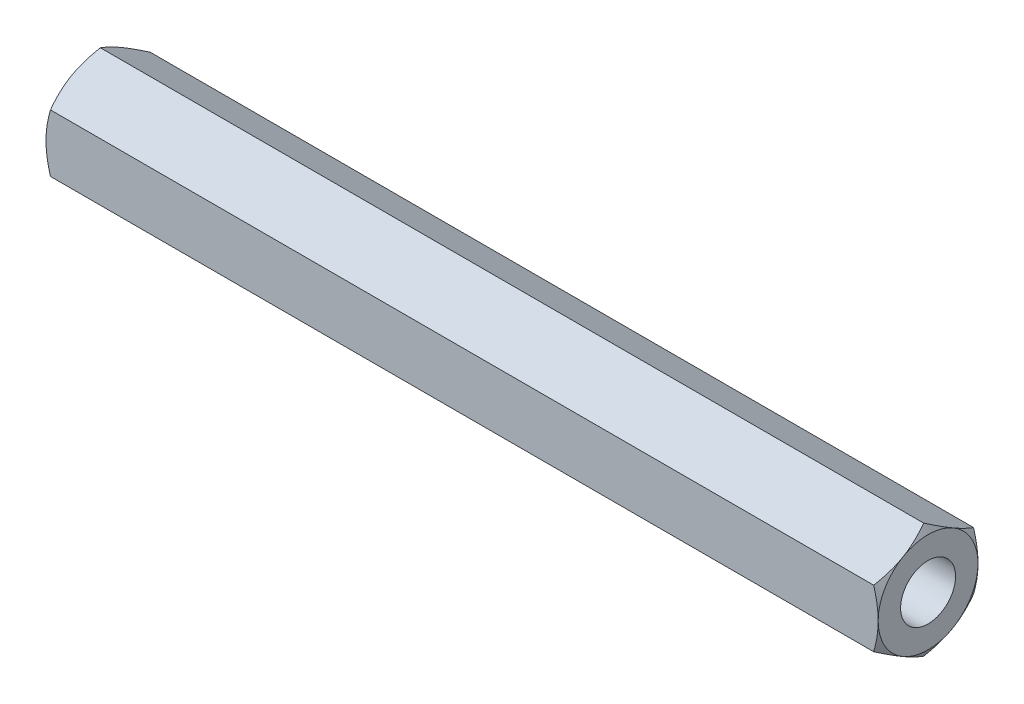
from build123d import *

# Parameters (mm, degrees)
BOSS_EXTRUDE1_DEPTH = 50
SKETCH21_W          = 50
SKETCH21_H          = 3
TAPPED_HOLE4_D      = 3.3
TAPPED_HOLE4_DEPTH  = 11.5
TAPPED_HOLE4_TIP    = 0.991420021
TAPPED_HOLE5_D      = 3.3
TAPPED_HOLE5_DEPTH  = 11.5
TAPPED_HOLE5_TIP    = 0.991420021


with BuildPart() as part:
    # Sketch1 → Boss-Extrude1 (new body)
    with BuildSketch(Plane(origin=(0, 0, 0), x_dir=(0, 0, -1), z_dir=(1, 0, 0))):
        Polygon((0, -3.464101615), (3, -1.732050808), (3, 1.732050808), (0, 3.464101615), (-3, 1.732050808), (-3, -1.732050808), align=None)
    extrude(amount=BOSS_EXTRUDE1_DEPTH)

    # Sketch2 → Cut-Revolve1 (revolve, cut)
    with BuildSketch(Plane.XY):
        Polygon((0, 3.464101615), (0.267949192, 3.464101615), (0, 3), align=None)
        Polygon((49.732050808, 3.464101615), (50, 3), (50, 3.464101615), align=None)
    revolve(axis=Axis((0, 0, 0), (1, 0, 0)), mode=Mode.SUBTRACT)

    # Sketch21 → Revolve1 (revolve)
    with BuildSketch(Plane.XY):
        with Locations((25, 1.5)):
            Rectangle(SKETCH21_W, SKETCH21_H)
    revolve(axis=Axis((0, 0, 0), (1, 0, 0)))

    # Tapped Hole4
    with Locations(Plane(origin=(0, -0.118657881, 0.00506752), x_dir=(0, 0, -1), z_dir=(-1, 0, 0))):
        with Locations((0.00506752, -0.118657881)):
            Hole(TAPPED_HOLE4_D / 2, depth=TAPPED_HOLE4_DEPTH)
            with Locations((0, 0, -(TAPPED_HOLE4_DEPTH + TAPPED_HOLE4_TIP / 2))):  # 118° drill point
                Cone(0, TAPPED_HOLE4_D / 2, TAPPED_HOLE4_TIP, mode=Mode.SUBTRACT)

    # Tapped Hole5
    with Locations(Plane(origin=(50, 0.843813549, 0.0751412), x_dir=(0, 0, -1), z_dir=(1, 0, 0))):
        with Locations((0.0751412, -0.843813549)):
            Hole(TAPPED_HOLE5_D / 2, depth=TAPPED_HOLE5_DEPTH)
            with Locations((0, 0, -(TAPPED_HOLE5_DEPTH + TAPPED_HOLE5_TIP / 2))):  # 118° drill point
                Cone(0, TAPPED_HOLE5_D / 2, TAPPED_HOLE5_TIP, mode=Mode.SUBTRACT)


solid = part.part
